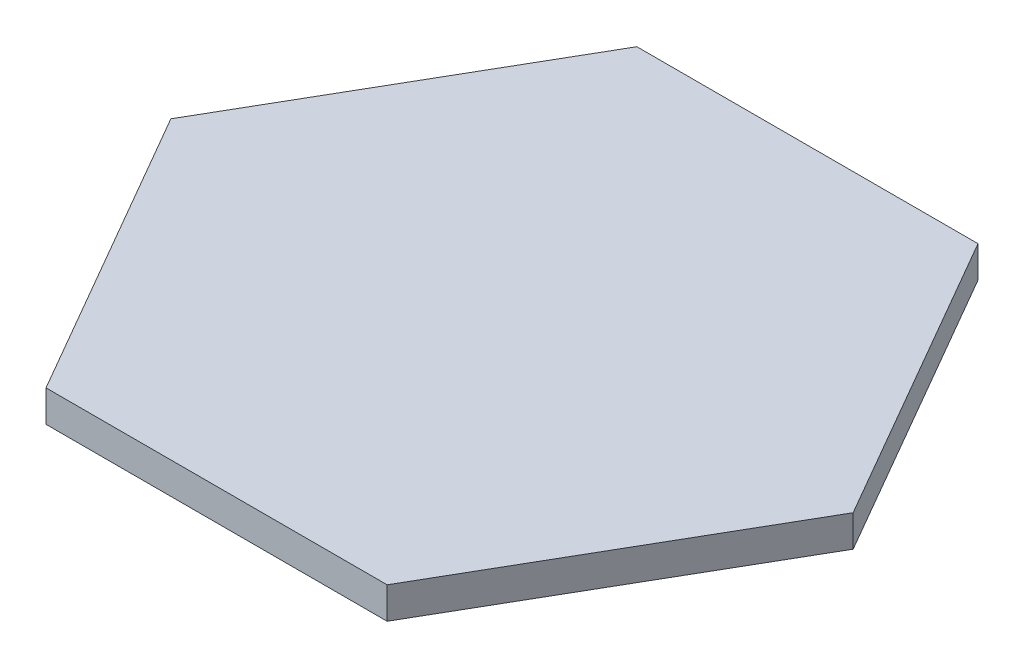
from build123d import *

# Parameters (mm, degrees)
BOSS_EXTRUDE1_DEPTH = 1


with BuildPart() as part:
    # Sketch1 → Boss-Extrude1 (new body)
    with BuildSketch(Plane(origin=(0, 0, 0), x_dir=(1, 0, 0), z_dir=(0, 1, 0))):
        Polygon((-5.398225017, -9.35), (5.398225017, -9.35), (10.796450034, 0), (5.398225017, 9.35), (-5.398225017, 9.35), (-10.796450034, 0), align=None)
    extrude(amount=BOSS_EXTRUDE1_DEPTH)


solid = part.part
